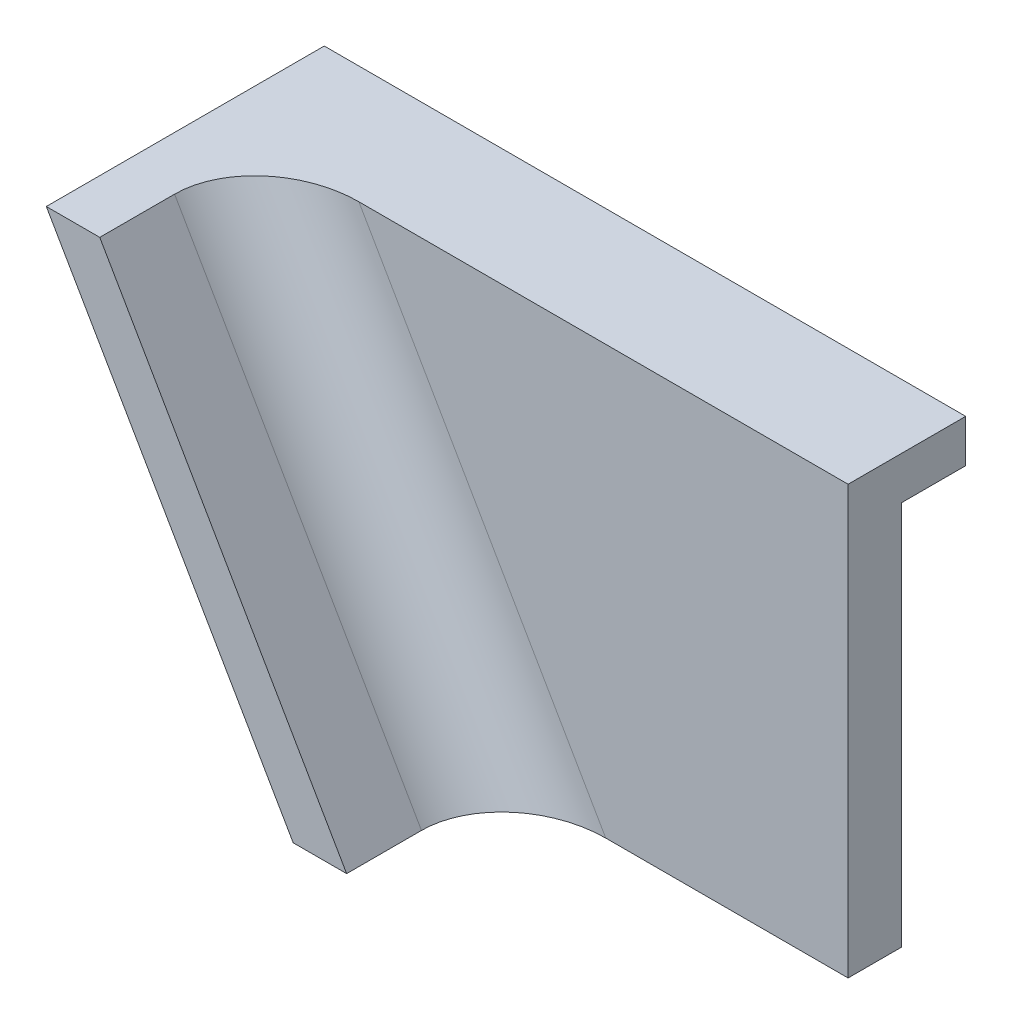
from build123d import *

# Parameters (mm, degrees)
BOSS_EXTRUDE1_DEPTH = 6.35
BOSS_EXTRUDE2_DEPTH = 7.62
BOSS_EXTRUDE3_DEPTH = 19.05
FILLET1_R           = 10.16


with BuildPart() as part:
    # Sketch1 → Boss-Extrude1 (new body)
    with BuildSketch(Plane.XY):
        Polygon((0, 0), (76.2, 0), (76.2, -50.8), (29.329393675, -50.8), align=None)
    extrude(amount=BOSS_EXTRUDE1_DEPTH)

    # Sketch2 → Boss-Extrude2 (add)
    with BuildSketch(Plane.XY):
        Polygon((76.2, 0), (0, 0), (2.932939367, -5.08), (76.2, -5.08), align=None)
    extrude(amount=-BOSS_EXTRUDE2_DEPTH)

    # Sketch3 → Boss-Extrude3 (add)
    with BuildSketch(Plane.XY.offset(6.35)):
        Polygon((29.329393675, -50.8), (35.679393675, -50.8), (6.35, 0), (0, 0), align=None)
    extrude(amount=BOSS_EXTRUDE3_DEPTH)

    # Fillet1
    fillet1_edges = [part.edges().sort_by_distance(p)[0] for p in [
        (21.014696837, -25.4, 6.35),
    ]]
    fillet(fillet1_edges, radius=FILLET1_R)


solid = part.part
